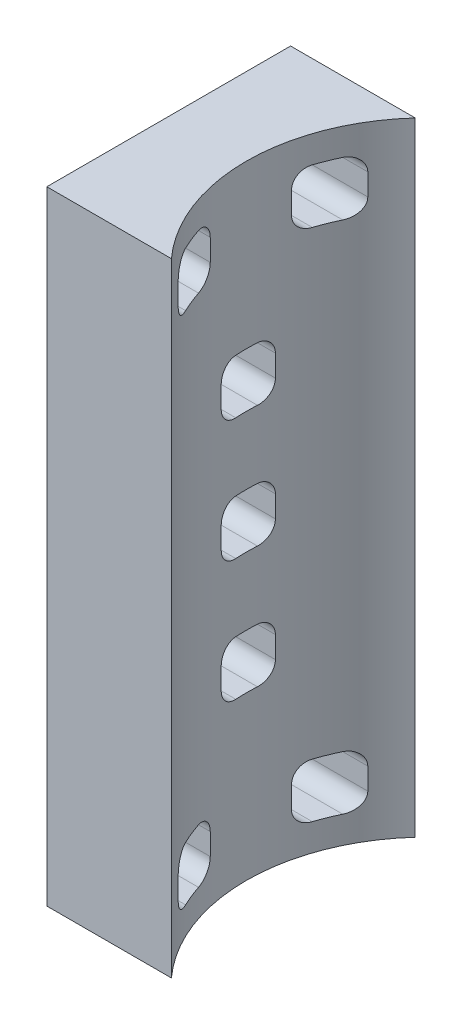
from build123d import *

# Parameters (mm, degrees)
SKETCH1_W           = 45
SKETCH1_H           = 115
BOSS_EXTRUDE1_DEPTH = 23
SKETCH2_R           = 33.5
CUT_EXTRUDE1_DEPTH  = 121
SKETCH3_W           = 10
SKETCH3_H           = 10
CUT_EXTRUDE3_DEPTH  = 31
FILLET2_R           = 3
FILLET3_R           = 3
SKETCH5_W           = 15
SKETCH5_H           = 1.5
SKETCH5_W_2         = 1.5
SKETCH5_H_2         = 12.5
SKETCH5_H_3         = 19.25
CUT_EXTRUDE4_DEPTH  = 3


with BuildPart() as part:
    # Sketch1 → Boss-Extrude1 (new body)
    with BuildSketch(Plane(origin=(0, 0, 0), x_dir=(0, 0, -1), z_dir=(1, 0, 0))):
        Rectangle(SKETCH1_W, SKETCH1_H)
    extrude(amount=BOSS_EXTRUDE1_DEPTH)

    # Sketch2 → Cut-Extrude1 (cut)
    with BuildSketch(Plane(origin=(0, 57.5, 0), x_dir=(1, 0, 0), z_dir=(0, 1, 0))):
        with Locations((47.819347292, 0)):
            Circle(SKETCH2_R)
    extrude(amount=-CUT_EXTRUDE1_DEPTH, mode=Mode.SUBTRACT)

    # Sketch3 → Cut-Extrude3 (cut)
    with BuildSketch(Plane.ZY):
        with Locations((12.5, -47.5)):
            Rectangle(SKETCH3_W, SKETCH3_H)
        with Locations((-12.5, -47.5)):
            Rectangle(SKETCH3_W, SKETCH3_H)
        with Locations((0, -22.5)):
            Rectangle(SKETCH3_W, SKETCH3_H)
        Rectangle(SKETCH3_W, SKETCH3_H)
        with Locations((0, 22.5)):
            Rectangle(SKETCH3_W, SKETCH3_H)
        with Locations((12.5, 47.5)):
            Rectangle(SKETCH3_W, SKETCH3_H)
        with Locations((-12.5, 47.5)):
            Rectangle(SKETCH3_W, SKETCH3_H)
    extrude(amount=-CUT_EXTRUDE3_DEPTH, mode=Mode.SUBTRACT)

    # Fillet2
    fillet2_edges = [part.edges().sort_by_distance(p)[0] for p in [
        (9.626816789, -42.5, 17.5),
        (9.626816789, -52.5, 17.5),
        (7.584845929, -42.5, 7.5),
        (7.584845929, 52.5, -7.5),
        (7.584845929, 42.5, -7.5),
        (9.626816789, 42.5, -17.5),
        (9.626816789, 52.5, -17.5),
        (9.626816789, 52.5, 17.5),
        (9.626816789, 42.5, 17.5),
        (7.584845929, 42.5, 7.5),
        (7.584845929, 52.5, 7.5),
        (7.347291571, 27.5, 5),
        (7.347291571, 17.5, 5),
        (7.347291571, 17.5, -5),
        (7.347291571, 27.5, -5),
        (7.347291571, 5, 5),
        (7.347291571, -5, 5),
        (7.347291571, -5, -5),
        (7.347291571, 5, -5),
        (7.347291571, -17.5, 5),
        (7.347291571, -27.5, 5),
        (7.347291571, -27.5, -5),
        (7.347291571, -17.5, -5),
        (7.584845929, -42.5, -7.5),
        (7.584845929, -52.5, -7.5),
        (9.626816789, -52.5, -17.5),
        (9.626816789, -42.5, -17.5),
    ]]
    fillet(fillet2_edges, radius=FILLET2_R)

    # Fillet3
    fillet3_edges = [part.edges().sort_by_distance(p)[0] for p in [
        (7.584845929, -52.5, 7.5),
    ]]
    fillet(fillet3_edges, radius=FILLET3_R)

    # Sketch5 → Cut-Extrude4 (cut)
    with BuildSketch(Plane.ZY):
        with Locations((0, -47.5)):
            Rectangle(SKETCH5_W, SKETCH5_H)
        with Locations((0, -11.25)):
            Rectangle(SKETCH5_W_2, SKETCH5_H_2)
        with Locations((0, -37.125)):
            Rectangle(SKETCH5_W_2, SKETCH5_H_3)
        with Locations((0, 11.25)):
            Rectangle(SKETCH5_W_2, SKETCH5_H_2)
        with Locations((0, 37.125)):
            Rectangle(SKETCH5_W_2, SKETCH5_H_3)
        with Locations((0, 47.5)):
            Rectangle(SKETCH5_W, SKETCH5_H)
    extrude(amount=-CUT_EXTRUDE4_DEPTH, mode=Mode.SUBTRACT)


solid = part.part
